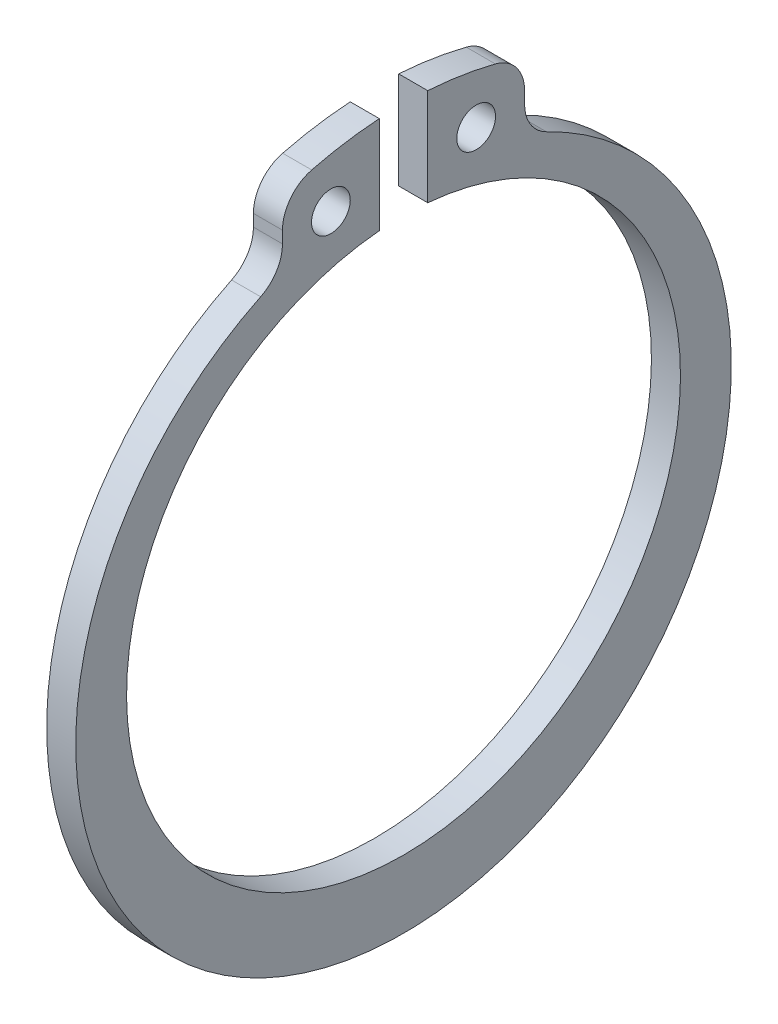
from build123d import *

# Parameters (mm, degrees)
SKETCH1_R           = 1
BOSS_EXTRUDE1_DEPTH = 1.5


with BuildPart() as part:
    # Sketch1 → Boss-Extrude1 (new body)
    with BuildSketch(Plane(origin=(0, 0, 0), x_dir=(0, 0, -1), z_dir=(1, 0, 0))):
        with BuildLine():
            Line((6.25, 16.157120391), (6.25, 16.769838997))
            ThreePointArc((6.25, 16.769838997), (5.828394576, 17.99811851), (4.741329439, 18.708548718))
            ThreePointArc((4.741329439, 18.708548718), (3.008303165, 19.064105331), (1.25, 19.259478186))
            Line((1.25, 19.259478186), (1.25, 14.24526237))
            ThreePointArc((1.25, 14.24526237), (0, -14.3), (-1.25, 14.24526237))
            Line((-1.25, 14.24526237), (-1.25, 19.259478186))
            ThreePointArc((-1.25, 19.259478186), (-3.008303352, 19.064105301), (-4.741329807, 18.708548625))
            ThreePointArc((-4.741329807, 18.708548625), (-5.828394693, 17.99811836), (-6.25, 16.769838997))
            Line((-6.25, 16.769838997), (-6.25, 16.157120391))
            ThreePointArc((-6.25, 16.157120391), (-6.555342891, 15.094982319), (-7.378137284, 14.357160556))
            ThreePointArc((-7.378137284, 14.357160556), (-5.6e-08, -17.8), (7.378137384, 14.357160508))
            ThreePointArc((7.378137384, 14.357160508), (6.555342921, 15.094982271), (6.25, 16.157120391))
        make_face()
        with Locations((3.75, 16.365864345)):
            Circle(SKETCH1_R, mode=Mode.SUBTRACT)
        with Locations((-3.75, 16.365864345)):
            Circle(SKETCH1_R, mode=Mode.SUBTRACT)
    extrude(amount=BOSS_EXTRUDE1_DEPTH)


solid = part.part
